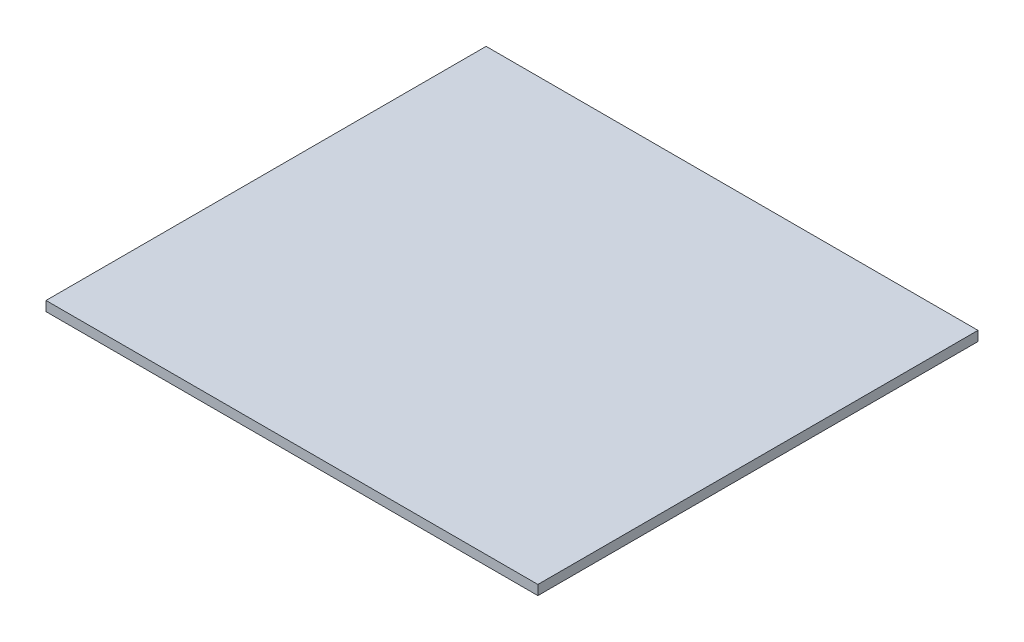
from build123d import *

# Parameters (mm, degrees)
SKETCH1_W           = 304
SKETCH1_H           = 272
BOSS_EXTRUDE1_DEPTH = 6


with BuildPart() as part:
    # Sketch1 → Boss-Extrude1 (new body)
    with BuildSketch(Plane(origin=(0, 0, 0), x_dir=(1, 0, 0), z_dir=(0, 1, 0))):
        with Locations((152, 136)):
            Rectangle(SKETCH1_W, SKETCH1_H)
    extrude(amount=BOSS_EXTRUDE1_DEPTH)


solid = part.part
